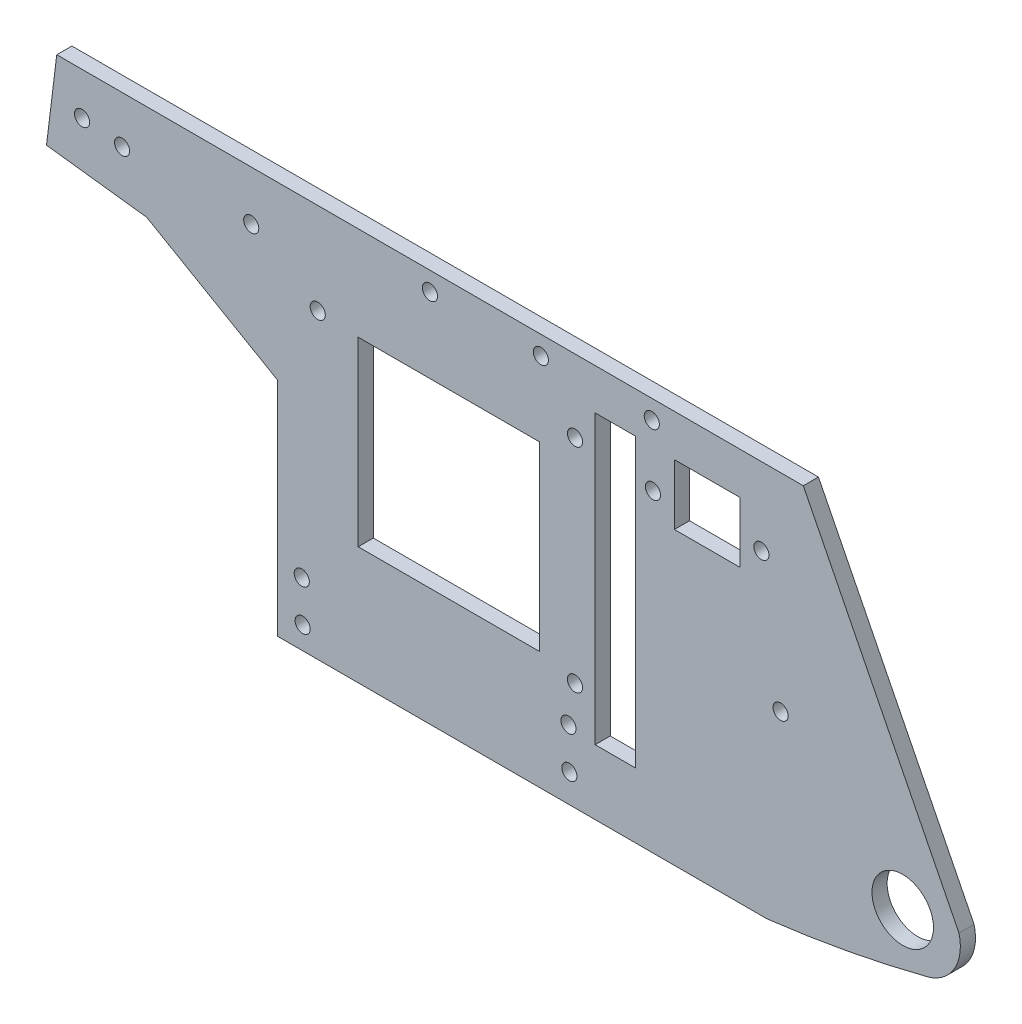
from build123d import *

# Parameters (mm, degrees)
EXTRUDE_1_DEPTH     = 3
CUT_EXTRUDE_1_REACH = 5
SKETCH_2_R          = 6.1
SKETCH_2_W          = 36
SKETCH_2_H          = 36
MM_CLEARANCE_1_D    = 3
MM_CLEARANCE_4_D    = 3
CUT_EXTRUDE_2_REACH = 5
SKETCH_18_R         = 1.5
MM_CLEARANCE_6_D    = 3
CUT_EXTRUDE_3_REACH = 5
SKETCH_21_W         = 13
SKETCH_21_H         = 12
MM_CLEARANCE_7_D    = 3
MM_CLEARANCE_10_D   = 3


with BuildPart() as part:
    # 草图1 → 凸台-拉伸1 (new body)
    with BuildSketch(Plane.XY):
        with BuildLine():
            Line((30.367519571, 31.798067496), (153.728402084, 31.798067496))
            Line((153.728402084, 31.798067496), (184.602796718, -29.595613307))
            ThreePointArc((184.602796718, -29.595613307), (183.670445617, -36.224755467), (178.320075375, -40.248229416))
            ThreePointArc((178.320075375, -40.248229416), (162.522923857, -43.753908616), (146.527707017, -46.201932504))
            Line((146.527707017, -46.201932504), (49.449368769, -46.201932504))
            Line((49.449368769, -46.201932504), (49.449368769, -2.201932504))
            Line((49.449368769, -2.201932504), (23.468606655, 12.798067496))
            Line((23.468606655, 12.798067496), (3.617683623, 15.235454364))
            Line((3.617683623, 15.235454364), (5.651316803, 31.798067496))
            Line((5.651316803, 31.798067496), (5.659575981, 31.798067496))
            Line((5.659575981, 31.798067496), (30.367519571, 31.798067496))
        make_face()
    extrude(amount=EXTRUDE_1_DEPTH)

    # 草图2 → 切除-拉伸1 (cut, up to next)
    with BuildSketch(Plane.XY.offset(3), mode=Mode.PRIVATE) as cut_extrude_1_sk1:
        with Locations((173.449368769, -31.201932504)):
            Circle(SKETCH_2_R)
    cut_extrude_1_tool1 = extrude(cut_extrude_1_sk1.sketch, amount=-CUT_EXTRUDE_1_REACH, mode=Mode.PRIVATE) & part.part
    add(cut_extrude_1_tool1.solids().sort_by_distance((173.449369, -31.201933, 3))[0], mode=Mode.SUBTRACT)
    # 草图2 → 切除-拉伸1 (cut, up to next)
    with BuildSketch(Plane.XY.offset(3), mode=Mode.PRIVATE) as cut_extrude_1_sk2:
        with Locations((83.439887491, -4.827295438)):
            Rectangle(SKETCH_2_W, SKETCH_2_H)
    cut_extrude_1_tool2 = extrude(cut_extrude_1_sk2.sketch, amount=-CUT_EXTRUDE_1_REACH, mode=Mode.PRIVATE) & part.part
    add(cut_extrude_1_tool2.solids().sort_by_distance((83.439887, -4.827295, 3))[0], mode=Mode.SUBTRACT)
    # 草图2 → 切除-拉伸1 (cut, up to next)
    with BuildSketch(Plane.XY.offset(3), mode=Mode.PRIVATE) as cut_extrude_1_sk3:
        Polygon((112.439887491, -4.827295438), (112.439887491, -33.327295438), (120.439887491, -33.327295438), (120.439887491, 23.672704562), (112.439887491, 23.672704562), align=None)
    cut_extrude_1_tool3 = extrude(cut_extrude_1_sk3.sketch, amount=-CUT_EXTRUDE_1_REACH, mode=Mode.PRIVATE) & part.part
    add(cut_extrude_1_tool3.solids().sort_by_distance((116.439887, -4.827295, 3))[0], mode=Mode.SUBTRACT)

    # 大小mm Clearance 暗销孔1 (through all)
    with Locations(Plane(origin=(141.673702765, 151.858231724, 3), x_dir=(-0.99978014, -0.020968354, 0), z_dir=(0, 0, 1))):
        with Locations((20.591231353, 123.39816829), (42.591231353, 122.936763059), (64.581557509, 122.475560716)):
            Hole(MM_CLEARANCE_1_D / 2)

    # 大小mm Clearance 暗销孔4 (through all)
    with Locations(Plane(origin=(141.673702765, 151.858231724, 3), x_dir=(-0.99978014, -0.020968354, 0), z_dir=(0, 0, 1))):
        with Locations((20.608818994, 135.452556109), (-0.900285243, 135.452556109)):
            Hole(MM_CLEARANCE_4_D / 2)

    # 草图18 → 切除-拉伸2 (cut, up to next)
    with BuildSketch(Plane.XY.offset(3), mode=Mode.PRIVATE) as cut_extrude_2_sk1:
        with Locations((149.222841692, -9.258973797)):
            Circle(SKETCH_18_R)
    cut_extrude_2_tool1 = extrude(cut_extrude_2_sk1.sketch, amount=-CUT_EXTRUDE_2_REACH, mode=Mode.PRIVATE) & part.part
    add(cut_extrude_2_tool1.solids().sort_by_distance((149.222842, -9.258974, 3))[0], mode=Mode.SUBTRACT)

    # 大小mm Clearance 暗销孔6 (through all)
    with Locations(Plane(origin=(141.673702765, 151.858231724, 3), x_dir=(-0.99978014, -0.020968354, 0), z_dir=(0, 0, 1))):
        with Locations((36.045400202, 133.709111751), (36.930668673, 175.919093371)):
            Hole(MM_CLEARANCE_6_D / 2)

    # 草图21 → 切除-拉伸3 (cut, up to next)
    with BuildSketch(Plane.XY.offset(3), mode=Mode.PRIVATE) as cut_extrude_3_sk1:
        with Locations((134.661819591, 17.503323217)):
            Rectangle(SKETCH_21_W, SKETCH_21_H)
    cut_extrude_3_tool1 = extrude(cut_extrude_3_sk1.sketch, amount=-CUT_EXTRUDE_3_REACH, mode=Mode.PRIVATE) & part.part
    add(cut_extrude_3_tool1.solids().sort_by_distance((134.66182, 17.503323, 3))[0], mode=Mode.SUBTRACT)

    # 大小mm Clearance 暗销孔7 (through all)
    with Locations(Plane(origin=(143.321207743, 150.868006211, 3), x_dir=(-0.99975237, -0.022253058, 0), z_dir=(0, 0, 1))):
        with Locations((88.938953066, 135.227377046), (101.942467158, 126.647536361), (127.53759353, 125.598807912), (135.454300746, 124.4473971)):
            Hole(MM_CLEARANCE_7_D / 2)

    # 大小mm Clearance 暗销孔10 (through all)
    with Locations(Plane(origin=(143.321207743, 150.868006211, 3), x_dir=(-0.99975237, -0.022253058, 0), z_dir=(0, 0, 1))):
        with Locations((93.161367469, 190.578219389), (93.161367469, 182.547127137), (40.245392963, 190.578219389), (40.245392963, 182.547127137)):
            Hole(MM_CLEARANCE_10_D / 2)


solid = part.part
